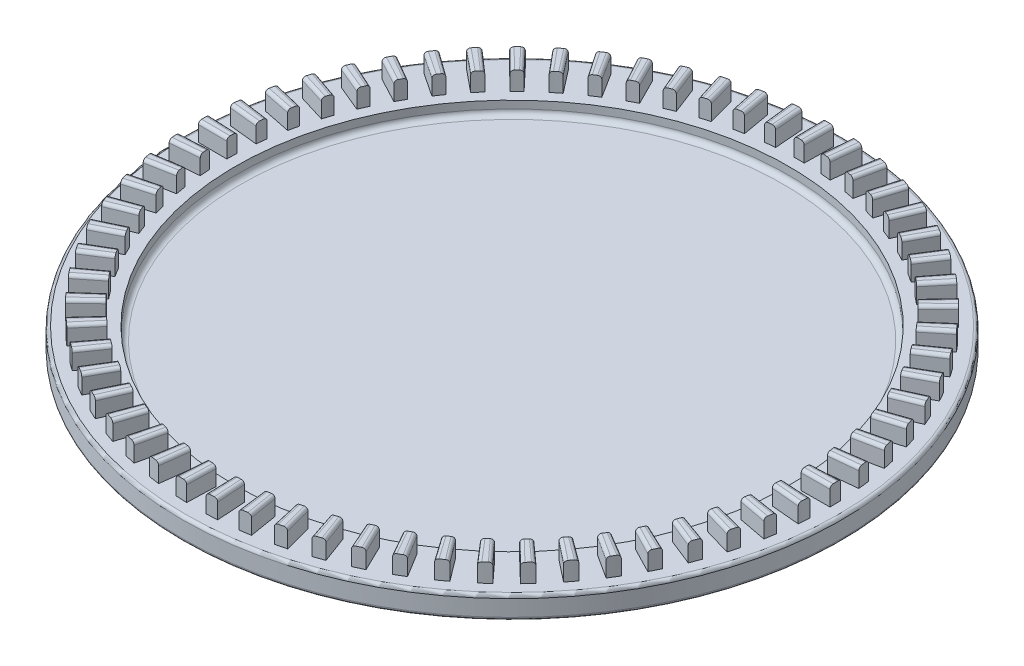
from build123d import *

# Parameters (mm, degrees)
BOSS_EXTRUDE1_DEPTH      = 1.75
FILLET1_R                = 0.3
CIRPATTERN2_COUNT        = 65
FILLET1_OF_CIRPATTERN2_R = 0.3


with BuildPart() as part:
    # Sketch3 → Revolve1 (revolve)
    with BuildSketch(Plane.XY):
        with BuildLine():
            Line((-30.8, 1.22), (-26.1, 1.22))
            Line((-26.1, 1.22), (-26.1, 0.5))
            ThreePointArc((-26.1, 0.5), (-25.953553391, 0.146446609), (-25.6, 0))
            Line((-25.6, 0), (0, 0))
            Line((0, 0), (0, -1.5))
            Line((0, -1.5), (-28.515120893, -1.5))
            ThreePointArc((-28.515120893, -1.5), (-29.770716153, -1.339781043), (-30.945843347, -0.869392217))
            ThreePointArc((-30.945843347, -0.869392217), (-31.058604915, -0.759292809), (-31.1, -0.607228684))
            Line((-31.1, -0.607228684), (-31.1, 0.92))
            ThreePointArc((-31.1, 0.92), (-31.012132034, 1.132132034), (-30.8, 1.22))
        make_face()
    revolve(axis=Axis((0, 249.903816833, 0), (0, -1, 0)))

    # Sketch5 → Boss-Extrude1 (add)
    with BuildSketch(Plane(origin=(0, 1.22, 0), x_dir=(1, 0, 0), z_dir=(0, 1, 0))):
        with BuildLine():
            ThreePointArc((-0.472960214, 27.095872539), (0, 27.1), (0.472960214, 27.095872539))
            Line((0.472960214, 27.095872539), (0.520081712, 29.795461316))
            ThreePointArc((0.520081712, 29.795461316), (0, 29.8), (-0.520081712, 29.795461316))
            Line((-0.520081712, 29.795461316), (-0.472960214, 27.095872539))
        make_face()
    boss_extrude1 = extrude(amount=BOSS_EXTRUDE1_DEPTH)

    # Fillet1
    fillet1_edges = [part.edges().sort_by_distance(p)[0] for p in [
        (-0.496520963, 2.97, -28.445666927),
        (0.496520963, 2.97, -28.445666927),
    ]]
    fillet(fillet1_edges, radius=FILLET1_R)

    # CirPattern2: Boss-Extrude1 ×65 about axis
    cirpattern2_axis = Axis((0, 0, 0), (0, 1, 0))
    for i in range(1, CIRPATTERN2_COUNT):
        add(boss_extrude1.rotate(cirpattern2_axis, i * 360 / CIRPATTERN2_COUNT))

    # Fillet1 of CirPattern2
    fillet1_of_cirpattern2_edges = [part.edges().sort_by_distance(p)[0] for p in [
        (-3.23960587, 2.97, -28.264950978),
        (-2.251199826, 2.97, -28.360793348),
        (-5.95244345, 2.97, -27.820332798),
        (-4.977901769, 2.97, -28.011122683),
        (-8.609704669, 2.97, -27.115963666),
        (-7.658126385, 2.97, -27.399919713),
        (-11.186579395, 2.97, -26.158420087),
        (-10.266849138, 2.97, -26.532891075),
        (-13.659008044, 2.97, -24.956642387),
        (-12.779713087, 2.97, -25.418131981),
        (-16.003906215, 2.97, -23.521851242),
        (-15.173256298, 2.97, -24.066050638),
        (-18.199380225, 2.97, -21.86744291),
        (-17.425130903, 2.97, -22.489271065),
        (-20.224931526, 2.97, -20.008864155),
        (-19.514311756, 2.97, -20.702515227),
        (-22.06164809, 2.97, -17.963468026),
        (-21.421292737, 2.97, -18.722465582),
        (-23.692380991, 2.97, -15.750351837),
        (-23.12826888, 2.97, -16.56760932),
        (-25.101904514, 2.97, -13.390178856),
        (-24.619302609, 2.97, -14.258065755),
        (-26.277058317, 2.97, -10.904985383),
        (-25.880472542, 2.97, -11.81539847),
        (-27.206870307, 2.97, -8.317974999),
        (-26.900003476, 2.97, -9.262413994),
        (-27.88265908, 2.97, -5.653301924),
        (-27.668376325, 2.97, -6.622948854),
        (-28.298114977, 2.97, -2.935845493),
        (-28.178417, 2.97, -3.921647025),
        (-28.449358999, 2.97, -0.190977863),
        (-28.425363387, 2.97, -1.183729835),
        (-28.334979022, 2.97, 2.555672876),
        (-28.406909815, 2.97, 1.565239522),
        (-27.956042979, 2.97, 5.278461986),
        (-28.12322858, 2.97, 4.29959466),
        (-27.316088896, 2.97, 7.951967519),
        (-27.576968337, 2.97, 6.99380564),
        (-26.421091851, 2.97, 10.551227673),
        (-26.773229371, 2.97, 9.622717342),
        (-25.27940819, 2.97, 13.051973857),
        (-25.719515976, 2.97, 12.161784325),
        (-23.901697506, 2.97, 15.430857279),
        (-24.42566639, 2.97, 14.587300004),
        (-22.300823112, 2.97, 17.665666943),
        (-22.903760938, 2.97, 16.876617993),
        (-20.491731941, 2.97, 19.735537035),
        (-21.168009241, 2.97, 19.008363548),
        (-18.491314991, 2.97, 21.621141735),
        (-19.234617546, 2.97, 20.962633133),
        (-16.318249614, 2.97, 23.30487566),
        (-17.121637409, 2.97, 22.721180261),
        (-13.992825138, 2.97, 24.77101824),
        (-14.848797156, 2.97, 24.267585851),
        (-11.536753423, 2.97, 26.005880497),
        (-12.437317686, 2.97, 25.58741153),
        (-8.972966151, 2.97, 26.997932855),
        (-9.909714331, 2.97, 26.668334442),
        (-6.32540071, 2.97, 27.737912788),
        (-7.289586643, 2.97, 27.5002623),
        (-3.618776708, 2.97, 28.218911303),
        (-4.601398049, 2.97, 28.075427619),
        (-0.878365163, 2.97, 28.436437446),
        (-1.870247441, 2.97, 28.388460235),
        (1.870247441, 2.97, 28.388460235),
        (0.878365163, 2.97, 28.436437446),
        (4.601398049, 2.97, 28.075427619),
        (3.618776708, 2.97, 28.218911303),
        (7.289586643, 2.97, 27.5002623),
        (6.32540071, 2.97, 27.737912788),
        (9.909714331, 2.97, 26.668334442),
        (8.972966151, 2.97, 26.997932855),
        (12.437317686, 2.97, 25.58741153),
        (11.536753423, 2.97, 26.005880497),
        (14.848797156, 2.97, 24.267585851),
        (13.992825138, 2.97, 24.77101824),
        (17.121637409, 2.97, 22.721180261),
        (16.318249614, 2.97, 23.30487566),
        (19.234617546, 2.97, 20.962633133),
        (18.491314991, 2.97, 21.621141735),
        (21.168009241, 2.97, 19.008363548),
        (20.491731941, 2.97, 19.735537035),
        (22.903760938, 2.97, 16.876617993),
        (22.300823112, 2.97, 17.665666943),
        (24.42566639, 2.97, 14.587300004),
        (23.901697506, 2.97, 15.430857279),
        (25.719515976, 2.97, 12.161784325),
        (25.27940819, 2.97, 13.051973857),
        (26.773229371, 2.97, 9.622717342),
        (26.421091851, 2.97, 10.551227673),
        (27.576968337, 2.97, 6.99380564),
        (27.316088896, 2.97, 7.951967519),
        (28.12322858, 2.97, 4.29959466),
        (27.956042979, 2.97, 5.278461986),
        (28.406909815, 2.97, 1.565239522),
        (28.334979022, 2.97, 2.555672876),
        (28.425363387, 2.97, -1.183729835),
        (28.449358999, 2.97, -0.190977863),
        (28.178417, 2.97, -3.921647025),
        (28.298114977, 2.97, -2.935845493),
        (27.668376325, 2.97, -6.622948854),
        (27.88265908, 2.97, -5.653301924),
        (26.900003476, 2.97, -9.262413994),
        (27.206870307, 2.97, -8.317974999),
        (25.880472542, 2.97, -11.81539847),
        (26.277058317, 2.97, -10.904985383),
        (24.619302609, 2.97, -14.258065755),
        (25.101904514, 2.97, -13.390178856),
        (23.12826888, 2.97, -16.56760932),
        (23.692380991, 2.97, -15.750351837),
        (21.421292737, 2.97, -18.722465582),
        (22.06164809, 2.97, -17.963468026),
        (19.514311756, 2.97, -20.702515227),
        (20.224931526, 2.97, -20.008864155),
        (17.425130903, 2.97, -22.489271065),
        (18.199380225, 2.97, -21.86744291),
        (15.173256298, 2.97, -24.066050638),
        (16.003906215, 2.97, -23.521851242),
        (12.779713087, 2.97, -25.418131981),
        (13.659008044, 2.97, -24.956642387),
        (10.266849138, 2.97, -26.532891075),
        (11.186579395, 2.97, -26.158420087),
        (7.658126385, 2.97, -27.399919713),
        (8.609704669, 2.97, -27.115963666),
        (4.977901769, 2.97, -28.011122683),
        (5.95244345, 2.97, -27.820332798),
        (2.251199826, 2.97, -28.360793348),
        (3.23960587, 2.97, -28.264950978),
    ]]
    fillet(fillet1_of_cirpattern2_edges, radius=FILLET1_OF_CIRPATTERN2_R)


solid = part.part
